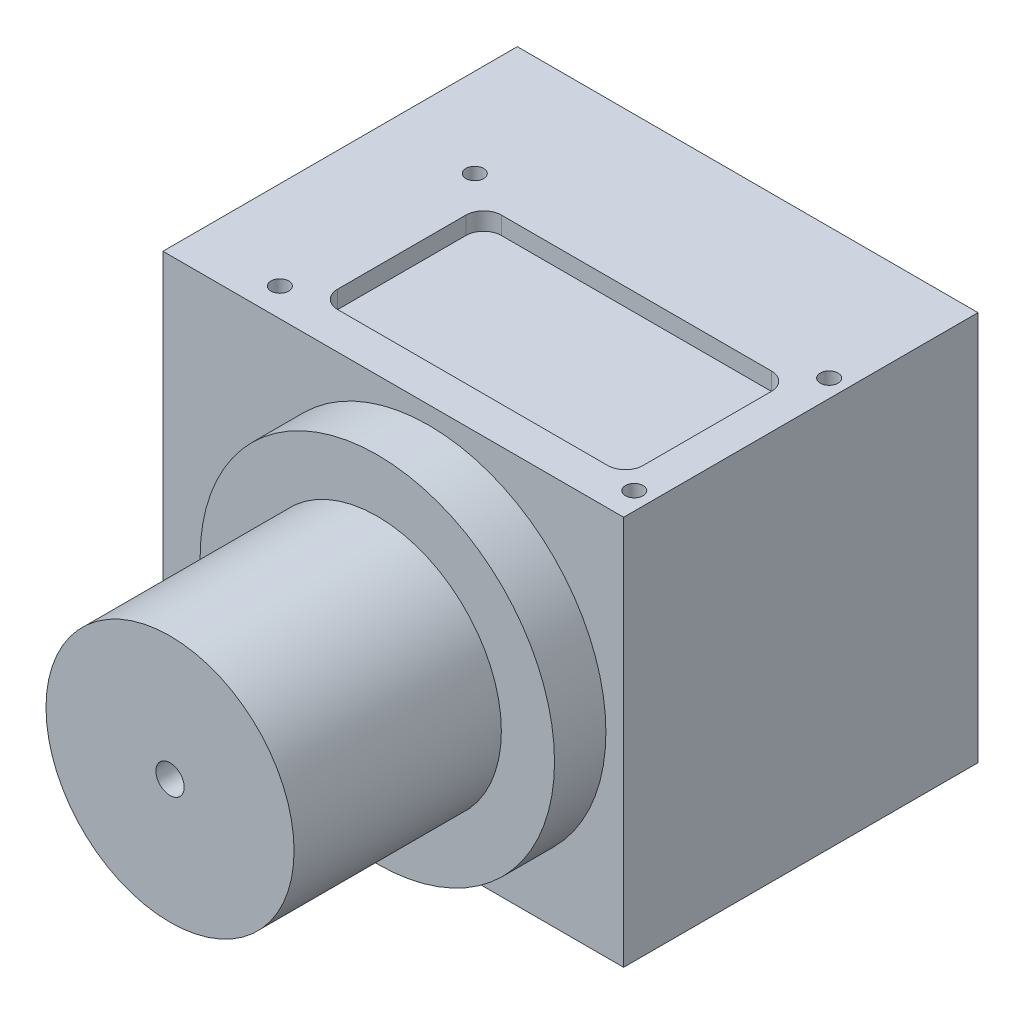
from build123d import *

# Parameters (mm, degrees)
SKETCH1_W           = 130
SKETCH1_H           = 100
SKETCH1_R           = 2.5
BOSS_EXTRUDE1_DEPTH = 110
CUT_EXTRUDE1_DEPTH  = 5
SKETCH3_R           = 26.593196083
CUT_EXTRUDE2_DEPTH  = 90
SKETCH4_R           = 3
CUT_EXTRUDE3_DEPTH  = 10
CUT_EXTRUDE4_DEPTH  = 20
SKETCH8_R           = 10
CUT_EXTRUDE5_DEPTH  = 10
SKETCH9_R           = 50
SKETCH9_R_2         = 14.996239462
BOSS_EXTRUDE3_DEPTH = 14.5
SKETCH10_R          = 35
SKETCH10_R_2        = 4
BOSS_EXTRUDE4_DEPTH = 58.5


with BuildPart() as part:
    # Sketch1 → Boss-Extrude1 (new body)
    with BuildSketch(Plane(origin=(0, 0, 0), x_dir=(1, 0, 0), z_dir=(0, 1, 0))):
        with Locations((65, -50)):
            Rectangle(SKETCH1_W, SKETCH1_H)
        with Locations(Location((25, -37, 0), (0, 0, 270))):  # turned: the seam where the file's is
            Circle(SKETCH1_R, mode=Mode.SUBTRACT)
        with Locations(Location((25, -92, 0), (0, 0, 270))):  # turned: the seam where the file's is
            Circle(SKETCH1_R, mode=Mode.SUBTRACT)
        with Locations(Location((125, -37, 0), (0, 0, 270))):  # turned: the seam where the file's is
            Circle(SKETCH1_R, mode=Mode.SUBTRACT)
        with Locations(Location((125, -92, 0), (0, 0, 270))):  # turned: the seam where the file's is
            Circle(SKETCH1_R, mode=Mode.SUBTRACT)
    extrude(amount=BOSS_EXTRUDE1_DEPTH)

    # Sketch2 → Cut-Extrude1 (cut)
    with BuildSketch(Plane(origin=(0, 110, 0), x_dir=(1, 0, 0), z_dir=(0, 1, 0))):
        with BuildLine():
            Line((38.9, -43.4), (115.1, -43.4))
            ThreePointArc((115.1, -43.4), (118.635533906, -44.864466094), (120.1, -48.4))
            Line((120.1, -48.4), (120.1, -84.6))
            ThreePointArc((120.1, -84.6), (118.635533906, -88.135533906), (115.1, -89.6))
            Line((115.1, -89.6), (38.9, -89.6))
            ThreePointArc((38.9, -89.6), (35.364466094, -88.135533906), (33.9, -84.6))
            Line((33.9, -84.6), (33.9, -48.4))
            ThreePointArc((33.9, -48.4), (35.364466094, -44.864466094), (38.9, -43.4))
        make_face()
    extrude(amount=-CUT_EXTRUDE1_DEPTH, mode=Mode.SUBTRACT)

    # Sketch3 → Cut-Extrude2 (cut)
    with BuildSketch(Plane(origin=(0, 0, 0), x_dir=(-1, 0, 0), z_dir=(0, 0, -1))):
        with Locations((-75, 55)):
            Circle(SKETCH3_R)
    extrude(amount=-CUT_EXTRUDE2_DEPTH, mode=Mode.SUBTRACT)

    # Sketch4 → Cut-Extrude3 (cut)
    with BuildSketch(Plane(origin=(0, 0, 0), x_dir=(-1, 0, 0), z_dir=(0, 0, -1))):
        with Locations((-125, 105)):
            Circle(SKETCH4_R)
        with Locations((-25, 105)):
            Circle(SKETCH4_R)
        with Locations((-125, 5)):
            Circle(SKETCH4_R)
        with Locations((-25, 5)):
            Circle(SKETCH4_R)
        with BuildLine():
            Line((-108, 108), (-42, 108))
            ThreePointArc((-42, 108), (-27.857864376, 102.142135624), (-22, 88))
            Line((-22, 88), (-22, 22))
            ThreePointArc((-22, 22), (-27.857864376, 7.857864376), (-42, 2))
            Line((-42, 2), (-108, 2))
            ThreePointArc((-108, 2), (-122.142135624, 7.857864376), (-128, 22))
            Line((-128, 22), (-128, 88))
            ThreePointArc((-128, 88), (-122.142135624, 102.142135624), (-108, 108))
        make_face()
    extrude(amount=-CUT_EXTRUDE3_DEPTH, mode=Mode.SUBTRACT)

    # Sketch6 → Cut-Extrude4 (cut)
    with BuildSketch(Plane.ZY):
        with BuildLine():
            Line((3, 13), (3, 97))
            ThreePointArc((3, 97), (5.928932188, 104.071067812), (13, 107))
            Line((13, 107), (87, 107))
            ThreePointArc((87, 107), (94.071067812, 104.071067812), (97, 97))
            Line((97, 97), (97, 13))
            ThreePointArc((97, 13), (94.071067812, 5.928932188), (87, 3))
            Line((87, 3), (13, 3))
            ThreePointArc((13, 3), (5.928932188, 5.928932188), (3, 13))
        make_face()
    extrude(amount=-CUT_EXTRUDE4_DEPTH, mode=Mode.SUBTRACT)

    # Sketch8 → Cut-Extrude5 (cut)
    with BuildSketch(Plane.XY.offset(100)):
        with Locations((75, 55)):
            Circle(SKETCH8_R)
    extrude(amount=-CUT_EXTRUDE5_DEPTH, mode=Mode.SUBTRACT)

    # Sketch9 → Boss-Extrude3 (add)
    with BuildSketch(Plane.XY.offset(100)):
        with Locations(Location((75, 55, 0), (0, 0, 180))):  # turned: the seam where the file's is
            Circle(SKETCH9_R)
        with Locations((75, 55)):
            Circle(SKETCH9_R_2, mode=Mode.SUBTRACT)
    extrude(amount=BOSS_EXTRUDE3_DEPTH)

    # Sketch10 → Boss-Extrude4 (add)
    with BuildSketch(Plane.XY.offset(114.5)):
        with Locations((75, 55)):
            Circle(SKETCH10_R)
        with Locations((75, 55)):
            Circle(SKETCH10_R_2, mode=Mode.SUBTRACT)
    extrude(amount=BOSS_EXTRUDE4_DEPTH)


solid = part.part
